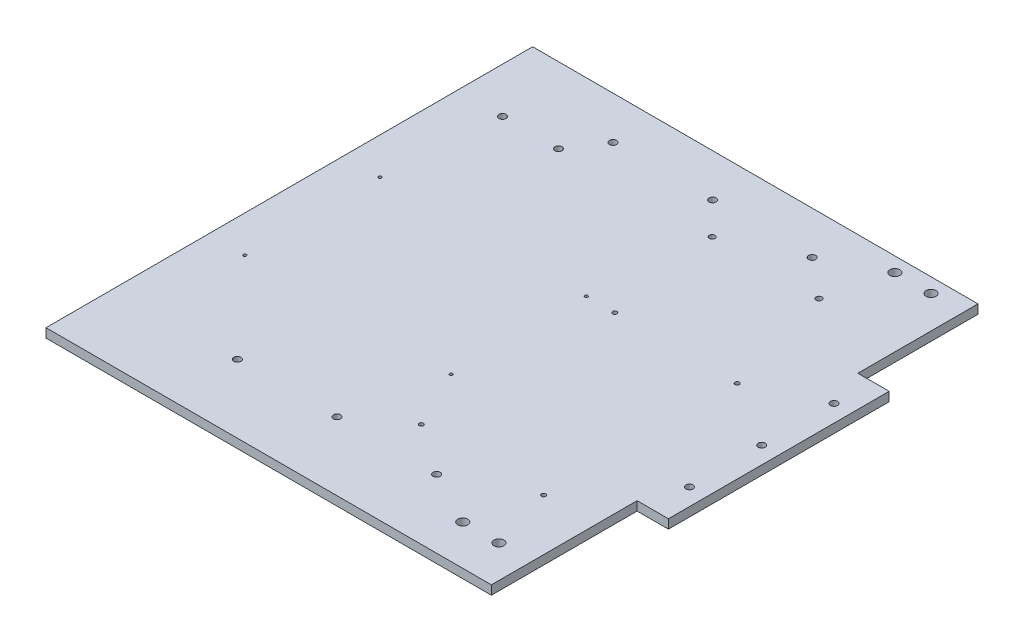
from build123d import *

# Parameters (mm, degrees)
SKETCH1_W           = 313
SKETCH1_H           = 342
BOSS_EXTRUDE1_DEPTH = 6.35
SKETCH3_W           = 22
SKETCH3_H           = 155.14040353
SKETCH3_R           = 2.5
BOSS_EXTRUDE2_DEPTH = 6.35
SKETCH2_R           = 2.5
CUT_EXTRUDE1_DEPTH  = 7.35
SKETCH4_R           = 3.5
CUT_EXTRUDE2_DEPTH  = 7.35
SKETCH5_R           = 2
SKETCH5_R_2         = 1.5
SKETCH5_R_3         = 1.05
SKETCH5_R_4         = 2.5
CUT_EXTRUDE3_DEPTH  = 7.35


with BuildPart() as part:
    # Sketch1 → Boss-Extrude1 (new body)
    with BuildSketch(Plane(origin=(0, 0, 0), x_dir=(1, 0, 0), z_dir=(0, 1, 0))):
        Rectangle(SKETCH1_W, SKETCH1_H)
    extrude(amount=-BOSS_EXTRUDE1_DEPTH)

    # Sketch3 → Boss-Extrude2 (add)
    with BuildSketch(Plane(origin=(0, 0, 0), x_dir=(1, 0, 0), z_dir=(0, 1, 0))):
        with Locations((167.5, 9)):
            Rectangle(SKETCH3_W, SKETCH3_H)
        with Locations((166.5, 9)):
            Circle(SKETCH3_R, mode=Mode.SUBTRACT)
        with Locations((166.5, -41.8)):
            Circle(SKETCH3_R, mode=Mode.SUBTRACT)
        with Locations((166.5, 59.8)):
            Circle(SKETCH3_R, mode=Mode.SUBTRACT)
    extrude(amount=-BOSS_EXTRUDE2_DEPTH)

    # Sketch2 → Cut-Extrude1 (cut, through all)
    with BuildSketch(Plane(origin=(0, 0, 0), x_dir=(1, 0, 0), z_dir=(0, 1, 0))):
        with Locations((0, -123)):
            Circle(SKETCH2_R)
        with Locations((-70, -123)):
            Circle(SKETCH2_R)
        with Locations((70, -123)):
            Circle(SKETCH2_R)
        with Locations((-70, 141)):
            Circle(SKETCH2_R)
        with Locations((0, 141)):
            Circle(SKETCH2_R)
        with Locations((70, 141)):
            Circle(SKETCH2_R)
    extrude(amount=-CUT_EXTRUDE1_DEPTH, mode=Mode.SUBTRACT)

    # Sketch4 → Cut-Extrude2 (cut, through all)
    with BuildSketch(Plane(origin=(0, 0, 0), x_dir=(1, 0, 0), z_dir=(0, 1, 0))):
        with Locations((133.64, -142.84)):
            Circle(SKETCH4_R)
        with Locations((108.24, -142.84)):
            Circle(SKETCH4_R)
    cut_extrude2 = extrude(amount=-CUT_EXTRUDE2_DEPTH, mode=Mode.SUBTRACT)

    # Mirror1: Cut-Extrude2 across plane
    add(cut_extrude2.mirror(Plane(origin=(0, 0, -9), x_dir=(1, 0, 0), z_dir=(0, 0, -1))), mode=Mode.SUBTRACT)

    # Sketch5 → Cut-Extrude3 (cut, through all)
    with BuildSketch(Plane(origin=(0, 0, 0), x_dir=(1, 0, 0), z_dir=(0, 1, 0))):
        with Locations((97.385625988, 118.365529647)):
            Circle(SKETCH5_R)
        with Locations((22.33428931, 118.365529647)):
            Circle(SKETCH5_R)
        with Locations((120.259039894, -98.018672219)):
            Circle(SKETCH5_R_2)
        with Locations((34.259039894, -98.018672219)):
            Circle(SKETCH5_R_2)
        with Locations((34.259039894, 37.981327781)):
            Circle(SKETCH5_R_2)
        with Locations((120.259039894, 37.981327781)):
            Circle(SKETCH5_R_2)
        with Locations((14.259039894, -57.018672219)):
            Circle(SKETCH5_R_3)
        with Locations((-130.740960106, -57.018672219)):
            Circle(SKETCH5_R_3)
        with Locations((14.259039894, 37.981327781)):
            Circle(SKETCH5_R_3)
        with Locations((-130.740960106, 37.981327781)):
            Circle(SKETCH5_R_3)
        with Locations((-85.31571069, 117.980264567)):
            Circle(SKETCH5_R_4)
        with Locations((-124.66571069, 117.980264567)):
            Circle(SKETCH5_R_4)
    extrude(amount=-CUT_EXTRUDE3_DEPTH, mode=Mode.SUBTRACT)


solid = part.part
